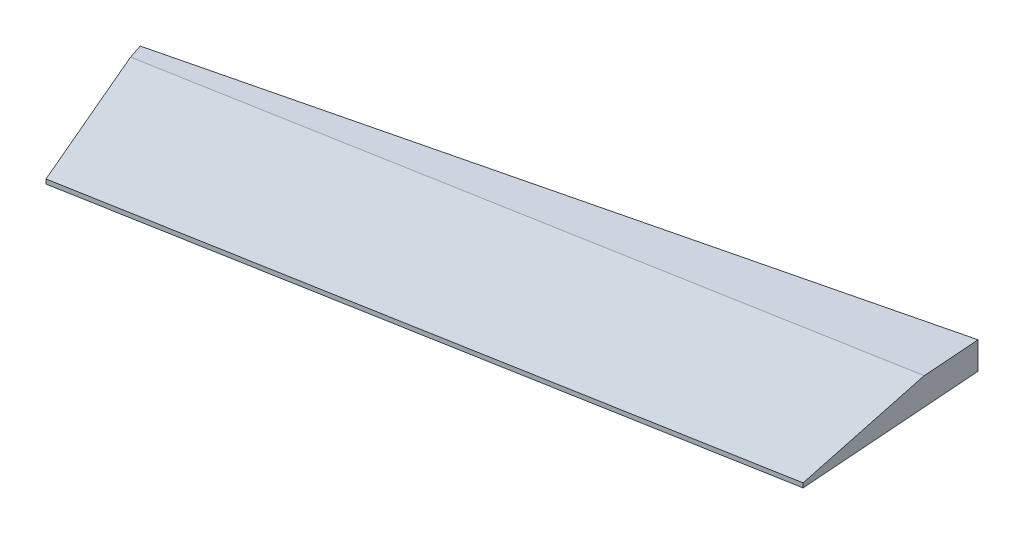
from build123d import *

# Parameters (mm, degrees)
BOSS_EXTRUDE1_DEPTH = 8.89
CHAMFER1_SIZE       = 7.46
CHAMFER1_SIZE2      = 42.307762374


with BuildPart() as part:
    # Sketch2 → Boss-Extrude1 (new body)
    with BuildSketch(Plane(origin=(0, 0, 0), x_dir=(1, 0, 0), z_dir=(0, 1, 0))):
        Polygon((133.286430852, -770.74001749), (147.934191067, -816.056525657), (356.664774137, -778.521640105), (352.263248298, -717.230631168), align=None)
    extrude(amount=-BOSS_EXTRUDE1_DEPTH)

    # Chamfer1
    chamfer1_edges = [part.edges().sort_by_distance(p)[0] for p in [
        (252.299482602, 0, 797.289082881),
    ]]
    chamfer1_side = [part.faces().sort_by_distance(p)[0] for p in [
        (252.299482602, -4.445, 797.289082881),
    ]]
    chamfer(chamfer1_edges, length=CHAMFER1_SIZE, length2=CHAMFER1_SIZE2, reference=chamfer1_side[0])


solid = part.part
